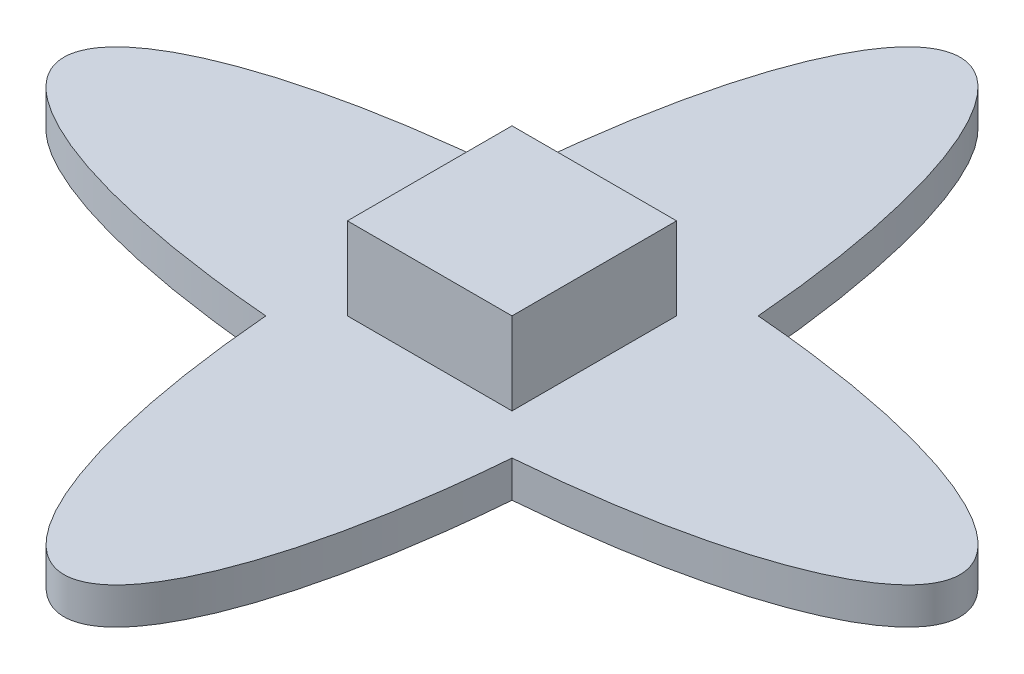
from build123d import *

# Parameters (mm, degrees)
BOSS_EXTRUDE1_DEPTH = 2
SKETCH2_W           = 9
SKETCH2_H           = 9
BOSS_EXTRUDE2_DEPTH = 4.5


with BuildPart() as part:
    # Sketch1 → Boss-Extrude1 (new body)
    with BuildSketch(Plane(origin=(0, 0, 0), x_dir=(1, 0, 0), z_dir=(0, 1, 0))):
        with BuildLine():
            add(Edge.make_bspline(
                [(-6.730667633, 6.730667633), (-89.181346144, 0), (-6.730667633, -6.730667633)],
                knots=[4.990688639, 4.990688639, 4.990688639, 7.575681975, 7.575681975, 7.575681975], degree=2, weights=[1, 0.274721128, 1]))
            add(Edge.make_bspline(
                [(-6.730667633, -6.730667633), (0, -89.181346144), (6.730667633, -6.730667633)],
                knots=[4.990688639, 4.990688639, 4.990688639, 7.575681975, 7.575681975, 7.575681975], degree=2, weights=[1, 0.274721128, 1]))
            add(Edge.make_bspline(
                [(6.730667633, -6.730667633), (89.181346144, 0), (6.730667633, 6.730667633)],
                knots=[1.849095986, 1.849095986, 1.849095986, 4.434089321, 4.434089321, 4.434089321], degree=2, weights=[1, 0.274721128, 1]))
            add(Edge.make_bspline(
                [(6.730667633, 6.730667633), (0, 89.181346144), (-6.730667633, 6.730667633)],
                knots=[1.849095986, 1.849095986, 1.849095986, 4.434089321, 4.434089321, 4.434089321], degree=2, weights=[1, 0.274721128, 1]))
        make_face()
    extrude(amount=BOSS_EXTRUDE1_DEPTH)

    # Sketch2 → Boss-Extrude2 (add)
    with BuildSketch(Plane(origin=(0, 2, 0), x_dir=(1, 0, 0), z_dir=(0, 1, 0))):
        Rectangle(SKETCH2_W, SKETCH2_H)
    extrude(amount=BOSS_EXTRUDE2_DEPTH)


solid = part.part
